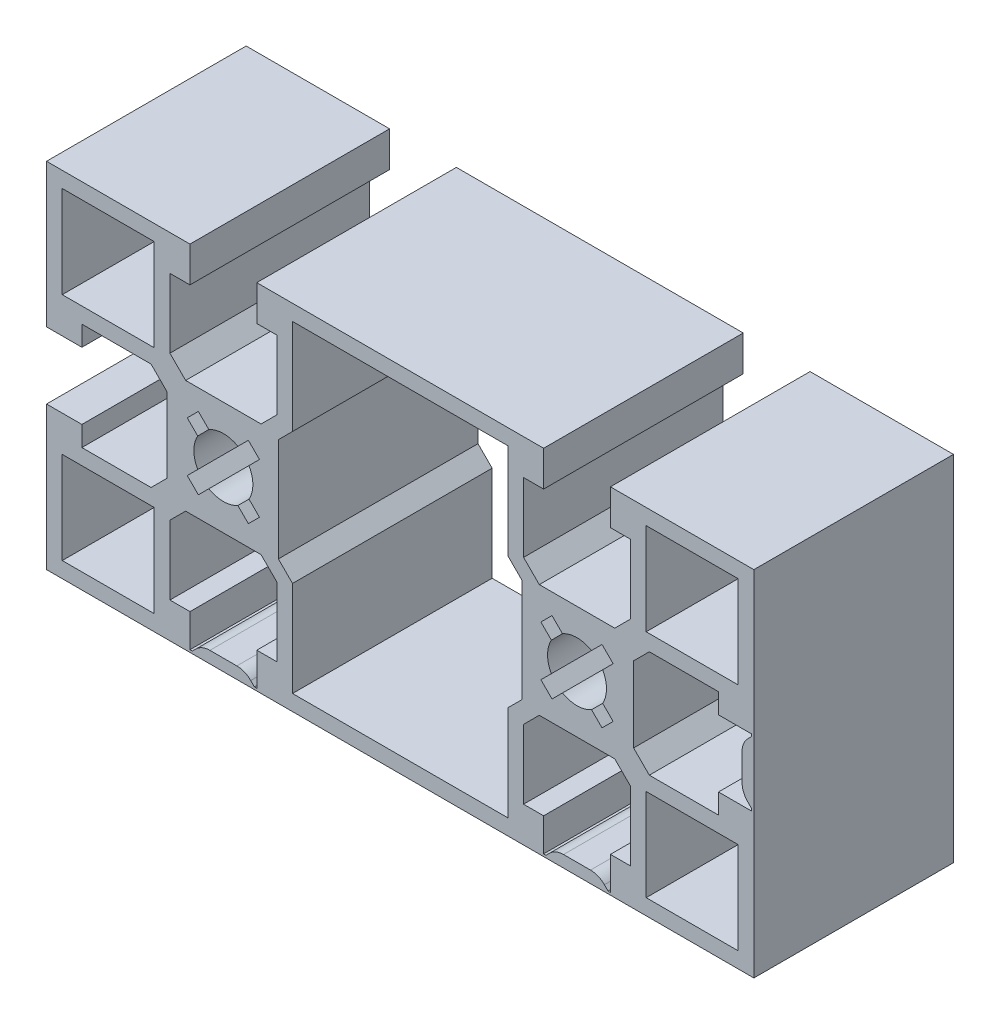
from build123d import *

# Parameters (mm, degrees)
BOSS_EXTRUDE1_DEPTH = 25.4


with BuildPart() as part:
    # Sketch1 → Boss-Extrude1 (new body)
    with BuildSketch(Plane.XY):
        Polygon((-45.000100804, -22.499999999), (44.999899202, -22.499999999), (44.999899202, 22.5), (26.749899972, 22.5), (26.749899972, 17.999999372), (29.299918194, 17.999999372), (29.299918002, 9.200011166), (27.299917722, 7.200011061), (17.699911829, 7.200011271), (15.699911706, 9.200011568), (15.699911899, 17.999999102), (18.249899884, 17.999999102), (18.249899884, 22.5), (-18.250100028, 22.5), (-18.250100028, 17.999999372), (-15.700081806, 17.999999372), (-15.700081998, 9.200011166), (-17.700082278, 7.200011061), (-27.300088171, 7.200011271), (-29.300088294, 9.200011568), (-29.300088101, 17.999999102), (-26.750100116, 17.999999102), (-26.750100116, 22.5), (-45.000100804, 22.5), (-45.000100804, 4.250000064), (-40.500099403, 4.250000064), (-40.500099403, 6.800018286), (-31.700111197, 6.800018094), (-29.700111092, 4.800017814), (-29.700111302, -4.79998808), (-31.700111599, -6.799988202), (-40.500099133, -6.79998801), (-40.500099133, -4.250000024), (-45.000100804, -4.250000024), align=None)
        with BuildLine():
            Line((19.237162182, 1.848524255), (17.903705922, 3.181980515))
            Line((17.903705922, 3.181980515), (19.317919485, 4.596194078))
            Line((19.317919485, 4.596194078), (20.651375745, 3.262737818))
            ThreePointArc((20.651375745, 3.262737818), (22.4999, 3.749999999), (24.348424255, 3.262737818))
            Line((24.348424255, 3.262737818), (25.681880515, 4.596194078))
            Line((25.681880515, 4.596194078), (27.096094078, 3.181980515))
            Line((27.096094078, 3.181980515), (25.762637818, 1.848524255))
            ThreePointArc((25.762637818, 1.848524255), (26.249899999, 0), (25.762637818, -1.848524255))
            Line((25.762637818, -1.848524255), (27.096094078, -3.181980515))
            Line((27.096094078, -3.181980515), (25.681880515, -4.596194078))
            Line((25.681880515, -4.596194078), (24.348424255, -3.262737818))
            ThreePointArc((24.348424255, -3.262737818), (22.4999, -3.749999999), (20.651375745, -3.262737818))
            Line((20.651375745, -3.262737818), (19.317919483, -4.596194079))
            Line((19.317919483, -4.596194079), (17.90370592, -3.181980517))
            Line((17.90370592, -3.181980517), (19.237162182, -1.848524255))
            ThreePointArc((19.237162182, -1.848524255), (18.749900001, 0), (19.237162182, 1.848524255))
        make_face(mode=Mode.SUBTRACT)
        with BuildLine():
            Line((-25.682080517, -4.596194079), (-27.09629408, -3.181980517))
            Line((-27.09629408, -3.181980517), (-25.762837818, -1.848524255))
            ThreePointArc((-25.762837818, -1.848524255), (-26.250099999, 0), (-25.762837818, 1.848524255))
            Line((-25.762837818, 1.848524255), (-27.096294078, 3.181980515))
            Line((-27.096294078, 3.181980515), (-25.682080515, 4.596194078))
            Line((-25.682080515, 4.596194078), (-24.348624255, 3.262737818))
            ThreePointArc((-24.348624255, 3.262737818), (-22.5001, 3.749999999), (-20.651575745, 3.262737818))
            Line((-20.651575745, 3.262737818), (-19.318119485, 4.596194078))
            Line((-19.318119485, 4.596194078), (-17.903905922, 3.181980515))
            Line((-17.903905922, 3.181980515), (-19.237362182, 1.848524255))
            ThreePointArc((-19.237362182, 1.848524255), (-18.750100001, 0), (-19.237362182, -1.848524255))
            Line((-19.237362182, -1.848524255), (-17.903905922, -3.181980515))
            Line((-17.903905922, -3.181980515), (-19.318119485, -4.596194078))
            Line((-19.318119485, -4.596194078), (-20.651575745, -3.262737818))
            ThreePointArc((-20.651575745, -3.262737818), (-22.5001, -3.749999999), (-24.348624255, -3.262737818))
            Line((-24.348624255, -3.262737818), (-25.682080517, -4.596194079))
        make_face(mode=Mode.SUBTRACT)
        Polygon((42.999881918, 20.500011944), (42.999881663, 8.8), (31.299899711, 8.8), (31.299899711, 20.5000122), align=None, mode=Mode.SUBTRACT)
        Polygon((42.999881952, -20.5), (31.2999, -20.5), (31.2999, -8.7999878), (42.999882208, -8.799988056), align=None, mode=Mode.SUBTRACT)
        Polygon((-31.300117792, -8.799988056), (-31.300118048, -20.5), (-43.0001, -20.5), (-43.0001, -8.7999878), align=None, mode=Mode.SUBTRACT)
        Polygon((-31.300118048, 8.8), (-43.0001, 8.8), (-43.0001, 20.5000122), (-31.300117792, 20.500011944), align=None, mode=Mode.SUBTRACT)
        with BuildLine():
            Line((-26.750099976, -22.200012315), (-26.750099976, -17.999999113))
            Line((-26.750099976, -17.999999113), (-29.300118194, -17.999999113))
            Line((-29.300118194, -17.999999113), (-29.300118002, -9.200011166))
            Line((-29.300118002, -9.200011166), (-27.300117722, -7.200011061))
            Line((-27.300117722, -7.200011061), (-17.700111829, -7.200011271))
            Line((-17.700111829, -7.200011271), (-15.700111706, -9.200011568))
            Line((-15.700111706, -9.200011568), (-15.700111899, -17.999998844))
            Line((-15.700111899, -17.999998844), (-18.250099887, -17.999998844))
            Line((-18.250099887, -17.999998844), (-18.250099887, -22.20001241))
            Line((-18.250099887, -22.20001241), (-18.550118283, -22.20001241))
            Line((-18.550118283, -22.20001241), (-19.017895639, -21.73223406))
            ThreePointArc((-19.017895639, -21.73223406), (-19.828954662, -21.190300811), (-20.785664471, -20.999999134))
            Line((-20.785664471, -20.999999134), (-24.214566009, -20.999999134))
            ThreePointArc((-24.214566009, -20.999999134), (-25.171313387, -21.190316374), (-25.982392349, -21.732291572))
            Line((-25.982392349, -21.732291572), (-26.450081665, -22.200012315))
            Line((-26.450081665, -22.200012315), (-26.750099976, -22.200012315))
        make_face(mode=Mode.SUBTRACT)
        with BuildLine():
            Line((18.249900024, -22.200012315), (18.249900024, -17.999999113))
            Line((18.249900024, -17.999999113), (15.699881806, -17.999999113))
            Line((15.699881806, -17.999999113), (15.699881998, -9.200011166))
            Line((15.699881998, -9.200011166), (17.699882278, -7.200011061))
            Line((17.699882278, -7.200011061), (27.299888171, -7.200011271))
            Line((27.299888171, -7.200011271), (29.299888294, -9.200011568))
            Line((29.299888294, -9.200011568), (29.299888101, -17.999998844))
            Line((29.299888101, -17.999998844), (26.749900113, -17.999998844))
            Line((26.749900113, -17.999998844), (26.749900113, -22.20001241))
            Line((26.749900113, -22.20001241), (26.449881717, -22.20001241))
            Line((26.449881717, -22.20001241), (25.982104361, -21.73223406))
            ThreePointArc((25.982104361, -21.73223406), (25.171045338, -21.190300811), (24.214335529, -20.999999134))
            Line((24.214335529, -20.999999134), (20.785433991, -20.999999134))
            ThreePointArc((20.785433991, -20.999999134), (19.828686613, -21.190316374), (19.017607651, -21.732291572))
            Line((19.017607651, -21.732291572), (18.549918335, -22.200012315))
            Line((18.549918335, -22.200012315), (18.249900024, -22.200012315))
        make_face(mode=Mode.SUBTRACT)
        with BuildLine():
            Line((31.699911166, -6.800018002), (29.699911061, -4.800017722))
            Line((29.699911061, -4.800017722), (29.699911271, 4.799988171))
            Line((29.699911271, 4.799988171), (31.699911568, 6.799988294))
            Line((31.699911568, 6.799988294), (40.499898813, 6.799988101))
            Line((40.499898813, 6.799988101), (40.499898813, 4.250000116))
            Line((40.499898813, 4.250000116), (44.69991241, 4.250000116))
            Line((44.69991241, 4.250000116), (44.69991241, 3.949981717))
            Line((44.69991241, 3.949981717), (44.23213406, 3.482204361))
            ThreePointArc((44.23213406, 3.482204361), (43.690200811, 2.671145338), (43.499899134, 1.714435529))
            Line((43.499899134, 1.714435529), (43.499899134, -1.714466009))
            ThreePointArc((43.499899134, -1.714466009), (43.690216374, -2.671213387), (44.232191572, -3.482292349))
            Line((44.232191572, -3.482292349), (44.699912315, -3.949981665))
            Line((44.699912315, -3.949981665), (44.699912315, -4.249999976))
            Line((44.699912315, -4.249999976), (40.499899113, -4.249999976))
            Line((40.499899113, -4.249999976), (40.499899113, -6.800018194))
            Line((40.499899113, -6.800018194), (31.699911166, -6.800018002))
        make_face(mode=Mode.SUBTRACT)
        Polygon((13.699911396, 20.5), (13.699911131, 8.37158507), (15.4999, 6.571596043), (15.4999, -6.571596043), (13.699910134, -8.371586067), (13.699910399, -20.5), (-13.7001122, -20.5), (-13.700111724, -8.371584476), (-15.5001, -6.571596043), (-15.5001, 6.571596848), (-13.700112474, 8.371584531), (-13.700112739, 20.5), align=None, mode=Mode.SUBTRACT)
    extrude(amount=BOSS_EXTRUDE1_DEPTH)


solid = part.part
